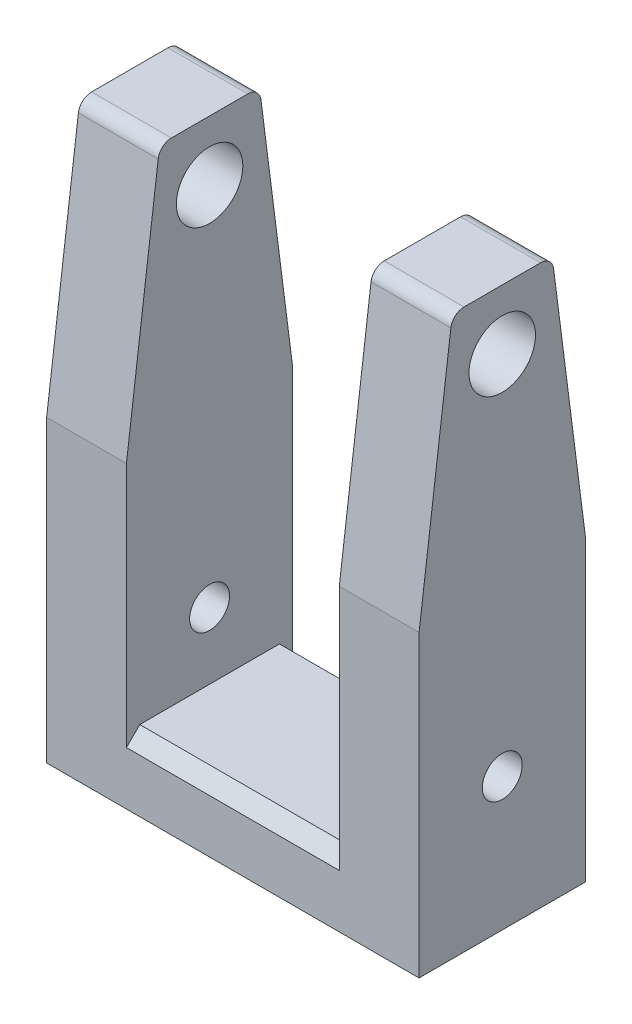
from build123d import *

# Parameters (mm, degrees)
SKETCH1_R           = 3
SKETCH1_R_2         = 5
BOSS_EXTRUDE1_DEPTH = 12
SKETCH3_W           = 25
SKETCH3_H           = 10
BOSS_EXTRUDE2_DEPTH = 16
CHAMFER1_SIZE       = 2


with BuildPart() as part:
    # Sketch1 → Boss-Extrude1 (new body)
    with BuildSketch(Plane(origin=(0, 0, 0), x_dir=(0, 0, -1), z_dir=(1, 0, 0))):
        with BuildLine():
            Line((-12.5, 45), (-7.723804022, 82.254328632))
            ThreePointArc((-7.723804022, 82.254328632), (-7.061279266, 83.501442184), (-5.740040692, 84))
            Line((-5.740040692, 84), (5.740040692, 84))
            ThreePointArc((5.740040692, 84), (7.061279266, 83.501442184), (7.723804022, 82.254328632))
            Line((7.723804022, 82.254328632), (12.5, 45))
            Line((12.5, 45), (12.5, 0))
            Line((12.5, 0), (-12.5, 0))
            Line((-12.5, 0), (-12.5, 45))
        make_face()
        with Locations((0, 20)):
            Circle(SKETCH1_R, mode=Mode.SUBTRACT)
        with Locations((0, 75)):
            Circle(SKETCH1_R_2, mode=Mode.SUBTRACT)
    extrude(amount=BOSS_EXTRUDE1_DEPTH)

    # Sketch3 → Boss-Extrude2 (add)
    with BuildSketch(Plane.ZY):
        with Locations((0, 5)):
            Rectangle(SKETCH3_W, SKETCH3_H)
    extrude(amount=BOSS_EXTRUDE2_DEPTH)

    # Mirror2: part across plane


with BuildPart() as part_1:
    add(part.part)
    add(part.part.mirror(Plane(origin=(-16, 0, 0), x_dir=(0, 0, 1), z_dir=(1, 0, 0))))

    # Chamfer1
    chamfer1_edges = [part_1.edges().sort_by_distance(p)[0] for p in [
        (-16, 10, -12.5),
        (-16, 10, 12.5),
    ]]
    chamfer(chamfer1_edges, length=CHAMFER1_SIZE)


solid = part_1.part
